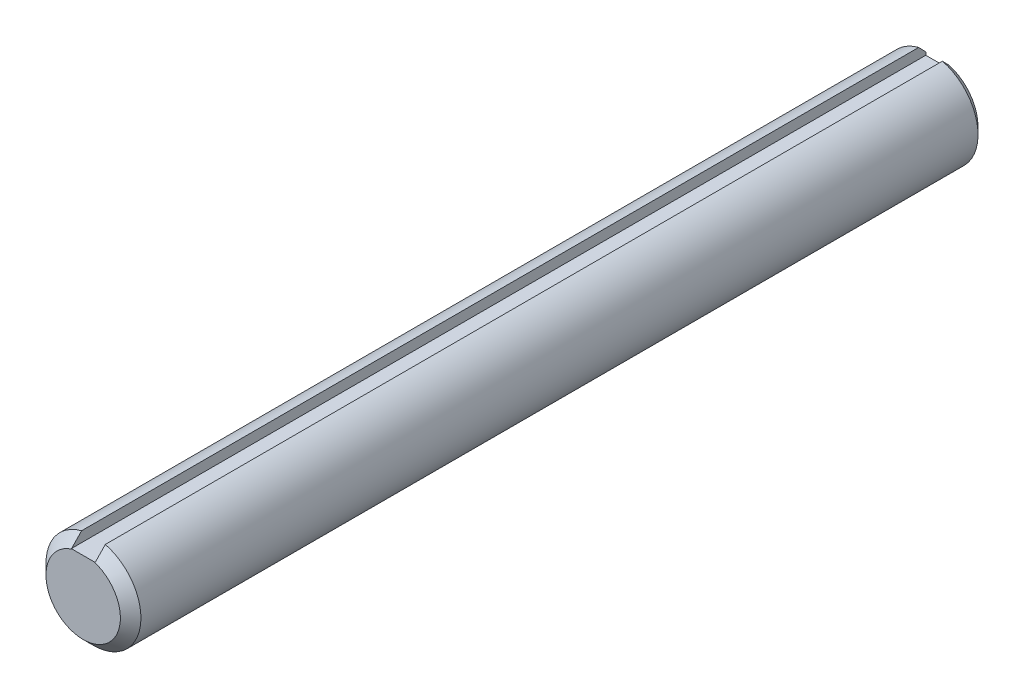
from build123d import *

# Parameters (mm, degrees)
SKETCH1_R           = 6.35
EXTRUDE1_DEPTH      = 76.2
CHAMFER1_SIZE       = 0.9525
SKETCH3_W           = 3.175
SKETCH3_H           = 1.5875
EXTRUDE2_DEPTH      = 77.727341932
EXTRUDE2_DEPTH_BACK = 77.727341932
CHAMFER2_SIZE       = 1.373522526


with BuildPart() as part:
    # Sketch1 → Extrude1 (new, symmetric)
    with BuildSketch(Plane.XY):
        with Locations(Location((0, 0, 0), (0, 0, 180))):
            Circle(SKETCH1_R)
    extrude(amount=EXTRUDE1_DEPTH, both=True)

    # Chamfer1
    chamfer1_edges = [part.edges().sort_by_distance(p)[0] for p in [
        (6.35, 0, -76.2),
        (6.35, 0, 76.2),
    ]]
    chamfer(chamfer1_edges, length=CHAMFER1_SIZE)

    # Sketch3 → Extrude2 (cut, two sides)
    with BuildSketch(Plane.XY) as extrude2_sk:
        with Locations((0, 5.55625)):
            Rectangle(SKETCH3_W, SKETCH3_H)
    extrude(amount=EXTRUDE2_DEPTH, mode=Mode.SUBTRACT)
    extrude(extrude2_sk.sketch, amount=-EXTRUDE2_DEPTH_BACK, mode=Mode.SUBTRACT)

    # SurfaceCut1
    split(bisect_by=Plane.XY.offset(38.1), keep=Keep.BOTTOM)

    # Chamfer2
    chamfer2_edges = [part.edges().sort_by_distance(p)[0] for p in [
        (0, -6.35, 38.1),
    ]]
    chamfer(chamfer2_edges, length=CHAMFER2_SIZE)


solid = part.part
